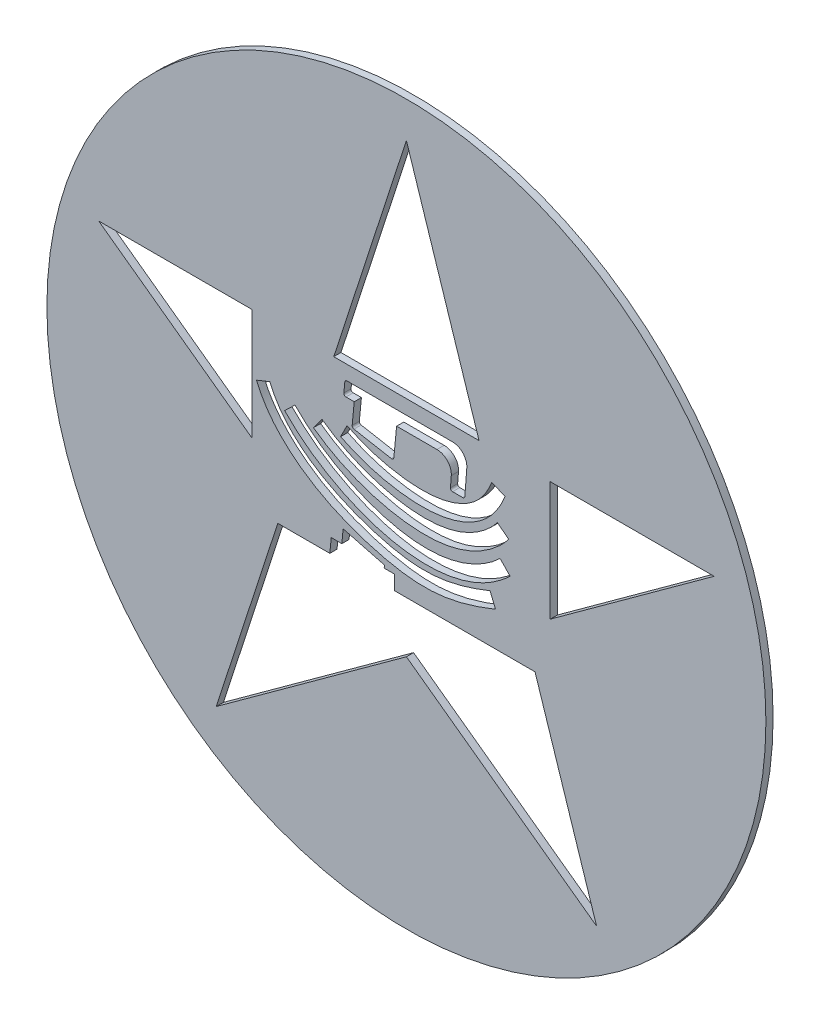
from build123d import *

# Parameters (mm, degrees)
SKETCH_1_R      = 5
EXTRUDE_3_DEPTH = 0.1


with BuildPart() as part:
    # 草图1 → 凸台-拉伸3 (new body)
    with BuildSketch(Plane.XY):
        Circle(SKETCH_1_R)
        Polygon((-0.167777112, -1.005793851), (1.720384349, -1.005793851), (1.788940866, -1.005793851), (2.645033635, -3.640576475), (0, -1.718847051), (-2.645033635, -3.640576475), (-1.788940866, -1.005793851), (-1.196984608, -1.005793851), (-1.064898778, -1.005793851), (-1.045698937, -0.805793851), (-0.898132968, -0.805793851), (-0.880039365, -0.617317259), (-0.305168214, -0.766751199), (-0.308916278, -0.805793851), (-0.167777112, -0.805793851), align=None, mode=Mode.SUBTRACT)
        with BuildLine():
            Line((-1.991956336, 0.60790071), (-1.899072205, 0.644948492))
            add(Edge.make_bspline(
                [(-1.899072205, 0.644948492), (-1.780698643, 0.348168911), (-1.304567249, -0.127672291), (-0.336736042, -0.504525958), (0.252920379, -0.581061249), (0.729572204, -0.501330005), (1.026706033, -0.397504088), (1.163445675, -0.341657163)],
                knots=[0, 0, 0, 0, 0.25, 0.5, 0.75, 0.875, 1, 1, 1, 1], degree=3))
            Line((1.163445675, -0.341657163), (1.201255585, -0.434233676))
            Line((1.201255585, -0.434233676), (1.239065495, -0.526810188))
            add(Edge.make_bspline(
                [(-2.084840467, 0.570852927), (-1.951454553, 0.236435213), (-1.399816024, -0.313391075), (-0.398090532, -0.695067628), (0.253747942, -0.784974301), (0.784004358, -0.694588239), (1.094323827, -0.585925285), (1.239065495, -0.526810188)],
                knots=[0, 0, 0, 0, 0.25, 0.5, 0.75, 0.875, 1, 1, 1, 1], degree=3))
            Line((-2.084840467, 0.570852927), (-1.991956336, 0.60790071))
        make_face(mode=Mode.SUBTRACT)
        Polygon((-4.279754323, 1.390576475), (-2.15, 1.390576475), (-2.15, -0.066596805), (-2.15, -0.156780615), align=None, mode=Mode.SUBTRACT)
        with BuildLine():
            add(Edge.make_bspline(
                [(-1.549830374, 0.538301968), (-1.367834784, 0.350062034), (-0.953039741, 0.039850566), (-0.14913383, -0.273116302), (0.644284758, -0.303181598), (1.121216686, -0.059789278), (1.302628316, 0.116501809)],
                knots=[0, 0, 0, 0, 0.25, 0.5, 0.75, 1, 1, 1, 1], degree=3))
            Line((1.302628316, 0.116501809), (1.372319625, 0.044786249))
            Line((1.372319625, 0.044786249), (1.442010933, -0.026929311))
            add(Edge.make_bspline(
                [(-1.693616475, 0.399285576), (-1.497925898, 0.196880775), (-1.049647981, -0.137319606), (-0.197096293, -0.473093583), (0.540683467, -0.49628987), (1.08406545, -0.311067402), (1.334925603, -0.130992039), (1.442010933, -0.026929311)],
                knots=[0, 0, 0, 0, 0.25, 0.5, 0.75, 0.875, 1, 1, 1, 1], degree=3))
            Line((-1.693616475, 0.399285576), (-1.621723425, 0.468793772))
            Line((-1.621723425, 0.468793772), (-1.549830374, 0.538301968))
        make_face(mode=Mode.SUBTRACT)
        with BuildLine():
            ThreePointArc((-0.840281876, 0.990576475), (-0.862451255, 1.000387117), (-0.870098497, 1.023392545))
            Line((-0.870098497, 1.023392545), (-0.856649718, 1.163485148))
            ThreePointArc((-0.856649718, 1.163485148), (-0.846976154, 1.182792155), (-0.826833098, 1.190576475))
            Line((-0.826833098, 1.190576475), (0.640511551, 1.190576475))
            ThreePointArc((0.640511551, 1.190576475), (0.787174219, 1.126554641), (0.839940758, 0.975477093))
            Line((0.839940758, 0.975477093), (0.812895447, 0.618268761))
            ThreePointArc((0.812895447, 0.618268761), (0.803392481, 0.598564726), (0.783027236, 0.590576475))
            Line((0.783027236, 0.590576475), (0.642533668, 0.590576475))
            ThreePointArc((0.642533668, 0.590576475), (0.620568222, 0.600164928), (0.612665457, 0.622791584))
            Line((0.612665457, 0.622791584), (0.617880458, 0.691670133))
            Line((0.617880458, 0.691670133), (0.624225734, 0.775477093))
            ThreePointArc((0.624225734, 0.775477093), (0.571459194, 0.926554641), (0.424796526, 0.990576475))
            Line((0.424796526, 0.990576475), (0.185889669, 0.990576475))
            Line((0.185889669, 0.990576475), (-0.136466154, 0.990576475))
            Line((-0.136466154, 0.990576475), (-0.174865836, 0.590576475))
            ThreePointArc((-0.174865836, 0.590576475), (-0.186605785, 0.569554584), (-0.210026076, 0.563965642))
            Line((-0.210026076, 0.563965642), (-0.730009604, 0.658240899))
            ThreePointArc((-0.730009604, 0.658240899), (-0.748550248, 0.669637431), (-0.754482606, 0.690576475))
            Line((-0.754482606, 0.690576475), (-0.725682844, 0.990576475))
            Line((-0.725682844, 0.990576475), (-0.840281876, 0.990576475))
        make_face(mode=Mode.SUBTRACT)
        Polygon((-1.010312947, 1.390576475), (0, 4.5), (1.010312947, 1.390576475), align=None, mode=Mode.SUBTRACT)
        with BuildLine():
            Line((-1.233981014, 0.474718903), (-1.175156308, 0.55558703))
            add(Edge.make_bspline(
                [(-1.175156308, 0.55558703), (-0.993921308, 0.423753933), (-0.60253903, 0.216218799), (0.110209984, 0.046440521), (0.771586805, 0.108296918), (1.136324529, 0.363638938), (1.265061247, 0.529994773)],
                knots=[0, 0, 0, 0, 0.25, 0.5, 0.75, 1, 1, 1, 1], degree=3))
            Line((1.265061247, 0.529994773), (1.344146249, 0.468793772))
            Line((1.344146249, 0.468793772), (1.423231251, 0.407592771))
            add(Edge.make_bspline(
                [(-1.29280572, 0.393850776), (-1.097129026, 0.251512571), (-0.673598325, 0.026850492), (0.090771832, -0.155398634), (0.834150505, -0.091874662), (1.271541178, 0.21157621), (1.423231251, 0.407592771)],
                knots=[0, 0, 0, 0, 0.25, 0.5, 0.75, 1, 1, 1, 1], degree=3))
            Line((-1.29280572, 0.393850776), (-1.233981014, 0.474718903))
        make_face(mode=Mode.SUBTRACT)
        with BuildLine():
            add(Edge.make_bspline(
                [(-0.824987307, 0.653212382), (-0.652216888, 0.565882813), (-0.294799178, 0.437574506), (0.340946716, 0.364657013), (0.791001776, 0.488979802), (1.051442622, 0.706562479), (1.151632496, 0.882886074), (1.184898576, 0.972197324)],
                knots=[0, 0, 0, 0, 0.25, 0.5, 0.75, 0.875, 1, 1, 1, 1], degree=3))
            Line((1.184898576, 0.972197324), (1.2786091, 0.937292631))
            Line((1.2786091, 0.937292631), (1.372319625, 0.902387938))
            add(Edge.make_bspline(
                [(-0.915209687, 0.474718903), (-0.728178948, 0.380181227), (-0.341272237, 0.241351144), (0.346598042, 0.160979838), (0.87745692, 0.299632533), (1.209299978, 0.577219377), (1.331357393, 0.792414409), (1.372319625, 0.902387938)],
                knots=[0, 0, 0, 0, 0.25, 0.5, 0.75, 0.875, 1, 1, 1, 1], degree=3))
            Line((-0.915209687, 0.474718903), (-0.870098497, 0.563965642))
            Line((-0.870098497, 0.563965642), (-0.824987307, 0.653212382))
        make_face(mode=Mode.SUBTRACT)
        Polygon((4.279754323, 1.390576475), (2, -0.265761995), (2, -0.022653284), (2, 1.390576475), align=None, mode=Mode.SUBTRACT)
    extrude(amount=EXTRUDE_3_DEPTH)


solid = part.part
